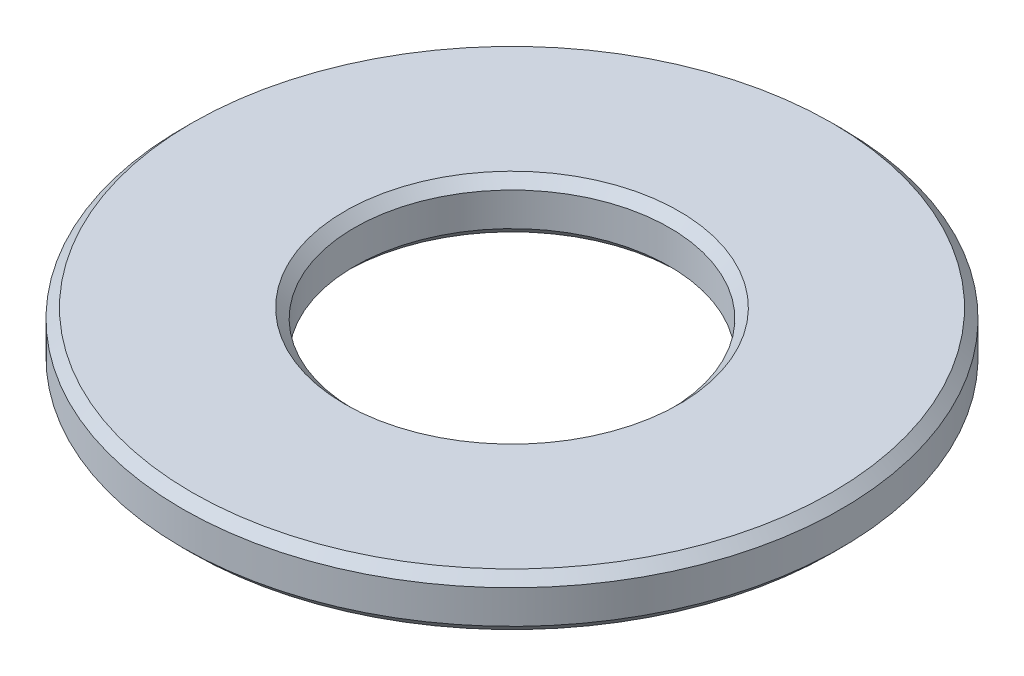
from build123d import *

# Parameters (mm, degrees)
SKIZZE1_R                       = 3.45
SKIZZE1_R_2                     = 1.65
AUFSATZ_LINEAR_AUSTRAGEN1_DEPTH = 0.55
FASE1_SIZE                      = 0.1


with BuildPart() as part:
    # Skizze1 → Aufsatz-Linear austragen1 (new body)
    with BuildSketch(Plane(origin=(0, 0, 0), x_dir=(1, 0, 0), z_dir=(0, 1, 0))):
        Circle(SKIZZE1_R)
        Circle(SKIZZE1_R_2, mode=Mode.SUBTRACT)
    extrude(amount=AUFSATZ_LINEAR_AUSTRAGEN1_DEPTH)

    # Fase1
    fase1_edges = [part.edges().sort_by_distance(p)[0] for p in [
        (-3.45, 0.55, 0),
        (-3.45, 0, 0),
        (-1.65, 0.55, 0),
        (-1.65, 0, 0),
    ]]
    chamfer(fase1_edges, length=FASE1_SIZE)


solid = part.part
